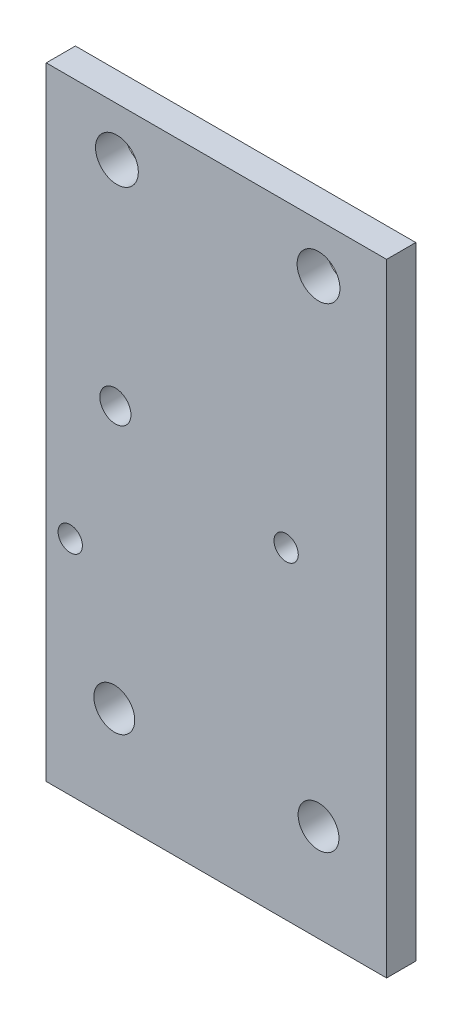
from build123d import *

# Parameters (mm, degrees)
SKETCH_1_W           = 40
SKETCH_1_H           = 29
EXTRUDE_1_DEPTH      = 3
CUT_EXTRUDE_1_DEPTH  = 3
SKETCH_3_W           = 40
SKETCH_3_H           = 3
EXTRUDE_2_DEPTH      = 10
SKETCH_4_W           = 40
SKETCH_4_H           = 3
EXTRUDE_3_DEPTH      = 10
SKETCH_6_W           = 3
SKETCH_6_H           = 49
EXTRUDE_5_DEPTH      = 42
SKETCH_8_W           = 3
SKETCH_8_H           = 49
EXTRUDE_6_DEPTH      = 2
SKETCH_9_W           = 3
SKETCH_9_H           = 49
EXTRUDE_7_DEPTH      = 2
SKETCH_10_W          = 86
SKETCH_10_H          = 3
EXTRUDE_8_DEPTH      = 10
SKETCH_11_W          = 86
SKETCH_11_H          = 3
EXTRUDE_9_DEPTH      = 10
SKETCH_14_W          = 3
SKETCH_14_H          = 69
CUT_EXTRUDE_5_DEPTH  = 43
SKETCH_17_W          = 43
SKETCH_17_H          = 3
EXTRUDE_10_DEPTH     = 20
SKETCH_18_R          = 2.1
CUT_EXTRUDE_6_DEPTH  = 10
SKETCH_20_W          = 43
SKETCH_20_H          = 3
EXTRUDE_11_DEPTH     = 10
SKETCH_21_W          = 43
SKETCH_21_H          = 3
CUT_EXTRUDE_7_DEPTH  = 20
SKETCH_24_R          = 2.2
CUT_EXTRUDE_8_DEPTH  = 30
SKETCH_27_R          = 1.6
CUT_EXTRUDE_9_DEPTH  = 10
SKETCH_28_W          = 3
SKETCH_28_H          = 79
CUT_EXTRUDE_10_DEPTH = 8
SKETCH_29_W          = 35
SKETCH_29_H          = 3
CUT_EXTRUDE_11_DEPTH = 15
M3X0_5_2_D           = 2.5
M3X0_5_2_DEPTH       = 8.5
M3X0_5_2_TIP         = 0.751075774


with BuildPart() as part:
    # ｽｹｯﾁ1 → ﾎﾞｽ - 押し出し1 (new body)
    with BuildSketch(Plane.XY):
        Rectangle(SKETCH_1_W, SKETCH_1_H)
    extrude(amount=EXTRUDE_1_DEPTH)

    # ｽｹｯﾁ2 → ｶｯﾄ - 押し出し1 (cut)
    with BuildSketch(Plane.XY.offset(3)):
        with BuildLine():
            ThreePointArc((-14.4, 10.5), (-15.01507576, 11.98492424), (-16.5, 12.6))
            Line((-16.5, 12.6), (-16.5, 10.5))
            Line((-16.5, 10.5), (-18.6, 10.5))
            ThreePointArc((-18.6, 10.5), (-16.5, 8.4), (-14.4, 10.5))
        make_face()
        with BuildLine():
            Line((-16.5, 10.5), (-16.5, 12.6))
            ThreePointArc((-16.5, 12.6), (-17.98492424, 11.98492424), (-18.6, 10.5))
            Line((-18.6, 10.5), (-16.5, 10.5))
        make_face()
        with BuildLine():
            ThreePointArc((-18.6, -10.5), (-17.98492424, -11.98492424), (-16.5, -12.6))
            Line((-16.5, -12.6), (-16.5, -10.5))
            Line((-16.5, -10.5), (-18.6, -10.5))
        make_face()
        with BuildLine():
            Line((-16.5, -10.5), (-16.5, -12.6))
            ThreePointArc((-16.5, -12.6), (-15.01507576, -11.98492424), (-14.4, -10.5))
            ThreePointArc((-14.4, -10.5), (-16.5, -8.4), (-18.6, -10.5))
            Line((-18.6, -10.5), (-16.5, -10.5))
        make_face()
        with BuildLine():
            ThreePointArc((18.6, -10.5), (15.01507576, -9.01507576), (16.5, -12.6))
            Line((16.5, -12.6), (16.5, -10.5))
            Line((16.5, -10.5), (18.6, -10.5))
        make_face()
        with BuildLine():
            Line((16.5, -10.5), (16.5, -12.6))
            ThreePointArc((16.5, -12.6), (17.98492424, -11.98492424), (18.6, -10.5))
            Line((18.6, -10.5), (16.5, -10.5))
        make_face()
        with BuildLine():
            ThreePointArc((18.6, 10.5), (17.98492424, 11.98492424), (16.5, 12.6))
            Line((16.5, 12.6), (16.5, 10.5))
            Line((16.5, 10.5), (18.6, 10.5))
        make_face()
        with BuildLine():
            Line((16.5, 10.5), (16.5, 12.6))
            ThreePointArc((16.5, 12.6), (15.01507576, 9.01507576), (18.6, 10.5))
            Line((18.6, 10.5), (16.5, 10.5))
        make_face()
    extrude(amount=-CUT_EXTRUDE_1_DEPTH, mode=Mode.SUBTRACT)

    # ｽｹｯﾁ3 → ﾎﾞｽ - 押し出し2 (add)
    with BuildSketch(Plane.XZ.offset(14.5)):
        with Locations((0, 1.5)):
            Rectangle(SKETCH_3_W, SKETCH_3_H)
    extrude(amount=EXTRUDE_2_DEPTH)

    # ｽｹｯﾁ4 → ﾎﾞｽ - 押し出し3 (add)
    with BuildSketch(Plane(origin=(0, 14.5, 0), x_dir=(1, 0, 0), z_dir=(0, 1, 0))):
        with Locations((0, -1.5)):
            Rectangle(SKETCH_4_W, SKETCH_4_H)
    extrude(amount=EXTRUDE_3_DEPTH)

    # ｽｹｯﾁ6 → ﾎﾞｽ - 押し出し5 (add)
    with BuildSketch(Plane(origin=(20, 0, 0), x_dir=(0, 0, -1), z_dir=(1, 0, 0))):
        with Locations((-1.5, 0)):
            Rectangle(SKETCH_6_W, SKETCH_6_H)
    extrude(amount=EXTRUDE_5_DEPTH)

    # ｽｹｯﾁ8 → ﾎﾞｽ - 押し出し6 (add)
    with BuildSketch(Plane.ZY.offset(20)):
        with Locations((1.5, 0)):
            Rectangle(SKETCH_8_W, SKETCH_8_H)
    extrude(amount=EXTRUDE_6_DEPTH)

    # ｽｹｯﾁ9 → ﾎﾞｽ - 押し出し7 (add)
    with BuildSketch(Plane(origin=(62, 0, 0), x_dir=(0, 0, -1), z_dir=(1, 0, 0))):
        with Locations((-1.5, 0)):
            Rectangle(SKETCH_9_W, SKETCH_9_H)
    extrude(amount=EXTRUDE_7_DEPTH)

    # ｽｹｯﾁ10 → ﾎﾞｽ - 押し出し8 (add)
    with BuildSketch(Plane.XZ.offset(24.5)):
        with Locations((21, 1.5)):
            Rectangle(SKETCH_10_W, SKETCH_10_H)
    extrude(amount=EXTRUDE_8_DEPTH)

    # ｽｹｯﾁ11 → ﾎﾞｽ - 押し出し9 (add)
    with BuildSketch(Plane(origin=(0, 24.5, 0), x_dir=(1, 0, 0), z_dir=(0, 1, 0))):
        with Locations((21, -1.5)):
            Rectangle(SKETCH_11_W, SKETCH_11_H)
    extrude(amount=EXTRUDE_9_DEPTH)

    # ｽｹｯﾁ14 → ｶｯﾄ - 押し出し5 (cut)
    with BuildSketch(Plane.ZY.offset(22)):
        with Locations((1.5, 0)):
            Rectangle(SKETCH_14_W, SKETCH_14_H)
    extrude(amount=-CUT_EXTRUDE_5_DEPTH, mode=Mode.SUBTRACT)

    # ｽｹｯﾁ17 → ﾎﾞｽ - 押し出し10 (add)
    with BuildSketch(Plane.XZ.offset(34.5)):
        with Locations((42.5, 1.5)):
            Rectangle(SKETCH_17_W, SKETCH_17_H)
    extrude(amount=EXTRUDE_10_DEPTH)

    # ｽｹｯﾁ18 → ｶｯﾄ - 押し出し6 (cut)
    with BuildSketch(Plane.XY.offset(3)):
        with Locations((36, -34.5)):
            Circle(SKETCH_18_R)
        with Locations((57, -34.5)):
            Circle(SKETCH_18_R)
    extrude(amount=-CUT_EXTRUDE_6_DEPTH, mode=Mode.SUBTRACT)

    # ｽｹｯﾁ20 → ﾎﾞｽ - 押し出し11 (add)
    with BuildSketch(Plane.XZ.offset(54.5)):
        with Locations((42.5, 1.5)):
            Rectangle(SKETCH_20_W, SKETCH_20_H)
    extrude(amount=EXTRUDE_11_DEPTH)

    # ｽｹｯﾁ21 → ｶｯﾄ - 押し出し7 (cut)
    with BuildSketch(Plane.XZ.offset(64.5)):
        with Locations((42.5, 1.5)):
            Rectangle(SKETCH_21_W, SKETCH_21_H)
    extrude(amount=-CUT_EXTRUDE_7_DEPTH, mode=Mode.SUBTRACT)

    # ｽｹｯﾁ24 → ｶｯﾄ - 押し出し8 (cut)
    with BuildSketch(Plane(origin=(0, 0, 0), x_dir=(-1, 0, 0), z_dir=(0, 0, -1))):
        with Locations((-36.27, 14.5)):
            Circle(SKETCH_24_R)
        with Locations((-57, 14.5)):
            Circle(SKETCH_24_R)
    extrude(amount=-CUT_EXTRUDE_8_DEPTH, mode=Mode.SUBTRACT)

    # ｽｹｯﾁ27 → ｶｯﾄ - 押し出し9 (cut)
    with BuildSketch(Plane(origin=(0, 0, 0), x_dir=(-1, 0, 0), z_dir=(0, 0, -1))):
        with Locations((-36.11, -7.5)):
            Circle(SKETCH_27_R)
    extrude(amount=-CUT_EXTRUDE_9_DEPTH, mode=Mode.SUBTRACT)

    # ｽｹｯﾁ28 → ｶｯﾄ - 押し出し10 (cut)
    with BuildSketch(Plane.ZY.offset(-21)):
        with Locations((1.5, -5)):
            Rectangle(SKETCH_28_W, SKETCH_28_H)
    extrude(amount=-CUT_EXTRUDE_10_DEPTH, mode=Mode.SUBTRACT)

    # ｽｹｯﾁ29 → ｶｯﾄ - 押し出し11 (cut)
    with BuildSketch(Plane(origin=(0, 34.5, 0), x_dir=(1, 0, 0), z_dir=(0, 1, 0))):
        with Locations((46.5, -1.5)):
            Rectangle(SKETCH_29_W, SKETCH_29_H)
    extrude(amount=-CUT_EXTRUDE_11_DEPTH, mode=Mode.SUBTRACT)

    # M3x0.5 ねじ穴2
    with Locations(Plane(origin=(31.47, -21.64, 3), x_dir=(1, 0, 0), z_dir=(0, 0, 1))):
        with Locations((0, 0), (22.2, 10.3)):
            Hole(M3X0_5_2_D / 2, depth=M3X0_5_2_DEPTH)
            with Locations((0, 0, -(M3X0_5_2_DEPTH + M3X0_5_2_TIP / 2))):  # 118° drill point
                Cone(0, M3X0_5_2_D / 2, M3X0_5_2_TIP, mode=Mode.SUBTRACT)


solid = part.part
